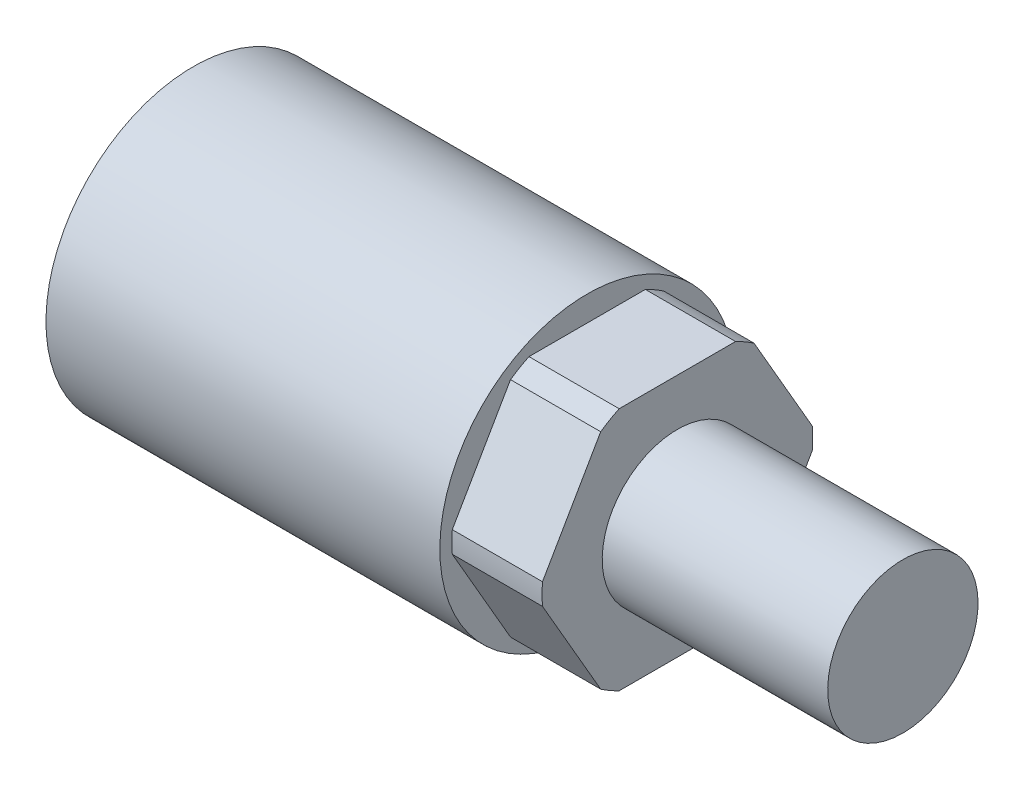
from build123d import *

# Parameters (mm, degrees)
SKETCH3_OUTSIDE_W  = 40.796
SKETCH3_OUTSIDE_H  = 40.796
CUT_EXTRUDE5_DEPTH = 7.62


with BuildPart() as part:
    # Sketch1 → Revolve1 (revolve)
    with BuildSketch(Plane.XY):
        Polygon((0, 11.43), (-7.62, 11.43), (-7.62, 12.446), (-40.894, 12.446), (-40.894, 0), (19.05, 0), (19.05, 6.35), (0, 6.35), align=None)
    revolve(axis=Axis((-40.894, 0, 0), (1, 0, 0)))

    # Sketch3 outside → Cut-Extrude5 (cut)
    with BuildSketch(Plane(origin=(0, 0, 0), x_dir=(0, 0, -1), z_dir=(1, 0, 0))):
        Rectangle(SKETCH3_OUTSIDE_W, SKETCH3_OUTSIDE_H)
        Polygon((5.95753309, 10.31875), (-5.95753309, 10.31875), (-11.91506618, 0), (-5.95753309, -10.31875), (5.95753309, -10.31875), (11.91506618, 0), align=None, mode=Mode.SUBTRACT)
    extrude(amount=-CUT_EXTRUDE5_DEPTH, mode=Mode.SUBTRACT)


solid = part.part
